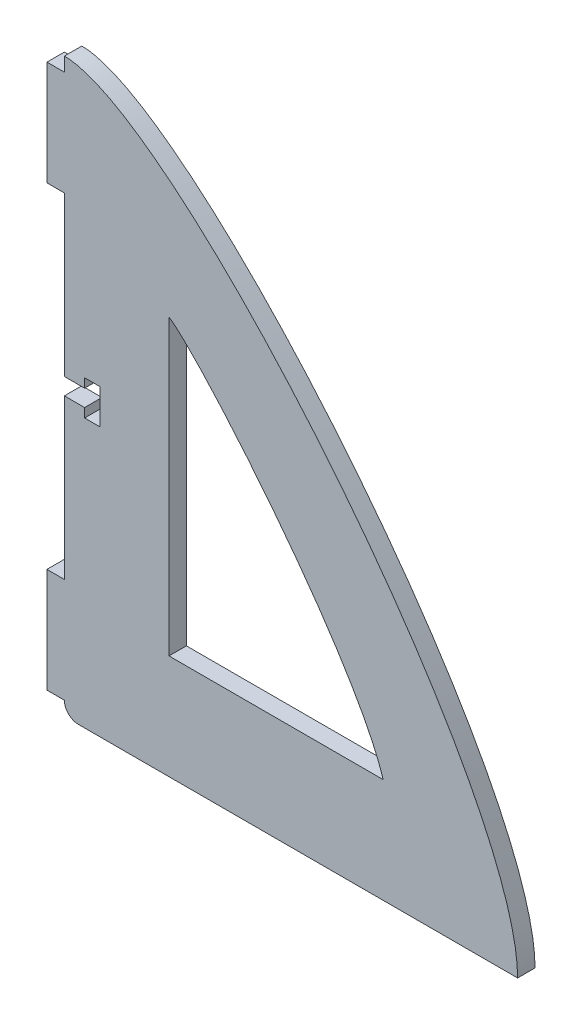
from build123d import *

# Parameters (mm, degrees)
BOSS_EXTRUDE1_DEPTH = 3.175


with BuildPart() as part:
    # Sketch1 → Boss-Extrude1 (new body)
    with BuildSketch(Plane.XY):
        with BuildLine():
            Line((0, 82.55), (0, 53.594))
            Line((0, 53.594), (3.683, 53.594))
            Line((3.683, 53.594), (3.683, 55.245))
            Line((3.683, 55.245), (6.477, 55.245))
            Line((6.477, 55.245), (6.477, 48.895))
            Line((6.477, 48.895), (3.683, 48.895))
            Line((3.683, 48.895), (3.683, 50.546))
            Line((3.683, 50.546), (0, 50.546))
            Line((0, 50.546), (0, 21.59))
            Line((0, 21.59), (-3.175, 21.59))
            Line((-3.175, 21.59), (-3.175, 2.54))
            Line((-3.175, 2.54), (0, 2.54))
            ThreePointArc((0, 2.54), (0.743948776, 0.743948776), (2.54, 0))
            Line((2.54, 0), (82.55, 0))
            add(Edge.make_bspline(
                [(0, 104.14), (20.815651588, 104.14), (82.55, 29.560059324), (82.55, 0)],
                knots=[0, 0, 0, 0, 1, 1, 1, 1], degree=3))
            Line((0, 104.14), (0, 101.6))
            Line((0, 101.6), (-3.175, 101.6))
            Line((-3.175, 101.6), (-3.175, 82.55))
            Line((-3.175, 82.55), (0, 82.55))
        make_face()
        with BuildLine():
            Line((19.05, 72.527700628), (19.05, 19.05))
            Line((19.05, 19.05), (58.0732756, 19.05))
            add(Edge.make_bspline(
                [(19.05, 72.527700628), (24.979605929, 68.637560894), (52.981970502, 35.459305466), (58.0732756, 19.05)],
                knots=[0, 0, 0, 0, 1, 1, 1, 1], degree=3))
        make_face(mode=Mode.SUBTRACT)
    extrude(amount=BOSS_EXTRUDE1_DEPTH)


solid = part.part
